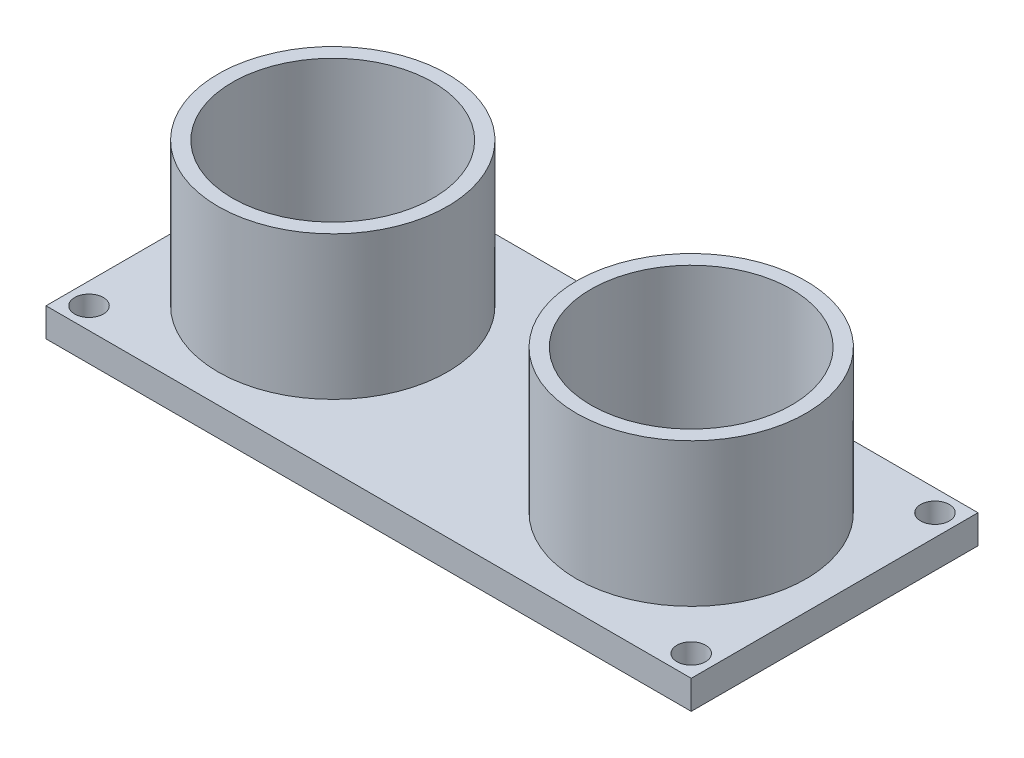
from build123d import *

# Parameters (mm, degrees)
SKETCH1_W           = 45
SKETCH1_H           = 20
SKETCH1_R           = 1
SKETCH1_R_2         = 8
SKETCH1_R_3         = 7
BOSS_EXTRUDE1_DEPTH = 2
SKETCH2_R           = 8
SKETCH2_R_2         = 7
BOSS_EXTRUDE2_DEPTH = 12


with BuildPart() as part:
    # Sketch1 → Boss-Extrude1 (new body)
    with BuildSketch(Plane(origin=(0, 0, 0), x_dir=(1, 0, 0), z_dir=(0, 1, 0))):
        Rectangle(SKETCH1_W, SKETCH1_H)
        with Locations(Location((-21, -8.5, 0), (0, 0, 270))):
            Circle(SKETCH1_R, mode=Mode.SUBTRACT)
        with Locations(Location((-21, 8.5, 0), (0, 0, 270))):
            Circle(SKETCH1_R, mode=Mode.SUBTRACT)
        with Locations((-12.5, 0)):
            Circle(SKETCH1_R_2, mode=Mode.SUBTRACT)
        with Locations(Location((21, -8.5, 0), (0, 0, 270))):
            Circle(SKETCH1_R, mode=Mode.SUBTRACT)
        with Locations(Location((21, 8.5, 0), (0, 0, 270))):
            Circle(SKETCH1_R, mode=Mode.SUBTRACT)
        with Locations((12.5, 0)):
            Circle(SKETCH1_R_2, mode=Mode.SUBTRACT)
        with Locations((-12.5, 0)):
            Circle(SKETCH1_R_2)
        with Locations((-12.5, 0)):
            Circle(SKETCH1_R_3, mode=Mode.SUBTRACT)
        with Locations((-12.5, 0)):
            Circle(SKETCH1_R_3)
        with Locations((12.5, 0)):
            Circle(SKETCH1_R_2)
        with Locations((12.5, 0)):
            Circle(SKETCH1_R_3, mode=Mode.SUBTRACT)
        with Locations((12.5, 0)):
            Circle(SKETCH1_R_3)
    extrude(amount=BOSS_EXTRUDE1_DEPTH)

    # Sketch2 → Boss-Extrude2 (add)
    with BuildSketch(Plane(origin=(0, 0, 0), x_dir=(1, 0, 0), z_dir=(0, 1, 0))):
        with Locations(Location((-12.5, 0, 0), (0, 0, 270))):
            Circle(SKETCH2_R)
        with Locations(Location((-12.5, 0, 0), (0, 0, 270))):
            Circle(SKETCH2_R_2, mode=Mode.SUBTRACT)
        with Locations(Location((12.5, 0, 0), (0, 0, 270))):
            Circle(SKETCH2_R)
        with Locations(Location((12.5, 0, 0), (0, 0, 270))):
            Circle(SKETCH2_R_2, mode=Mode.SUBTRACT)
    extrude(amount=BOSS_EXTRUDE2_DEPTH)


solid = part.part
